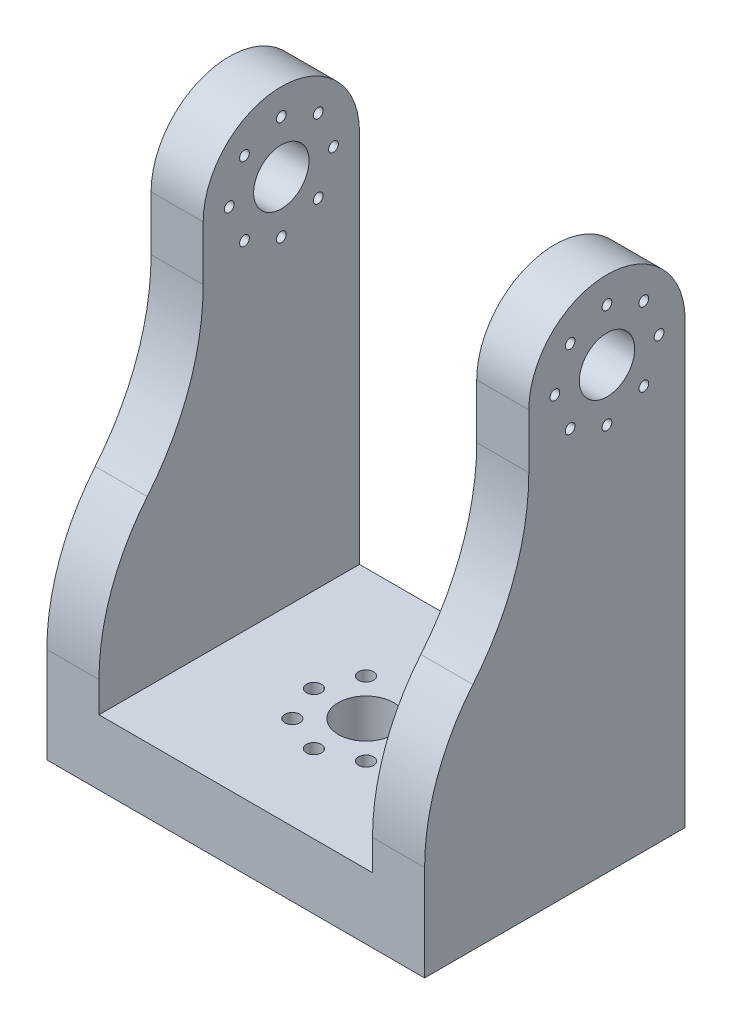
from build123d import *

# Parameters (mm, degrees)
DODANIE_WYCI_GNI_CIE1_DEPTH = 40
SZKIC2_R                    = 4.25
WYTNIJ_WYCI_GNI_CIE1_DEPTH  = 107.60206377
SZKIC3_R                    = 4.25
SZKIC3_R_2                  = 0.65
WYTNIJ_WYCI_GNI_CIE2_DEPTH  = 86.301617521
SZKIC4_R                    = 0.75
WYTNIJ_WYCI_GNI_CIE3_DEPTH  = 107.254891017
SZKIC3_3_R                  = 1.15
SZKIC3_3_R_2                = 0.65
WYTNIJ_WYCI_GNI_CIE4_DEPTH  = 4


with BuildPart() as part:
    # Szkic1 → Dodanie-wyci_gni_cie1 (new body)
    with BuildSketch(Plane.XY):
        Polygon((21, 10), (-21, 10), (-21, 80), (-29, 80), (-29, 0), (29, 0), (29, 80), (21, 80), align=None)
    extrude(amount=DODANIE_WYCI_GNI_CIE1_DEPTH)

    # Szkic2 → Wytnij-wyci_gni_cie1 (cut, through all)
    with BuildSketch(Plane(origin=(29, 0, 0), x_dir=(0, 0, -1), z_dir=(1, 0, 0))):
        with BuildLine():
            ThreePointArc((-24, 67.536795667), (-12, 79.536795667), (0, 67.536795667))
            Line((0, 67.536795667), (0, 80))
            Line((0, 80), (-40, 80))
            Line((-40, 80), (-40, 14.688889066))
            ThreePointArc((-40, 14.688889066), (-38.089938994, 25.648227934), (-32.584991767, 35.315233546))
            ThreePointArc((-32.584991767, 35.315233546), (-26.211441646, 46.507556061), (-24, 59.196123761))
            Line((-24, 59.196123761), (-24, 67.536795667))
        make_face()
        with Locations((-12, 67.536795667)):
            Circle(SZKIC2_R)
    extrude(amount=-WYTNIJ_WYCI_GNI_CIE1_DEPTH, mode=Mode.SUBTRACT)

    # Szkic3 → Wytnij-wyci_gni_cie2 (cut, through all)
    with BuildSketch(Plane(origin=(0, 10, 0), x_dir=(1, 0, 0), z_dir=(0, 1, 0))):
        with Locations((0, -20)):
            Circle(SZKIC3_R)
        with Locations((0, -12)):
            Circle(SZKIC3_R_2)
        with Locations((0, -28)):
            Circle(SZKIC3_R_2)
        with Locations((5.656854249, -25.656854249)):
            Circle(SZKIC3_R_2)
        with Locations((8, -20)):
            Circle(SZKIC3_R_2)
        with Locations((-5.656854249, -25.656854249)):
            Circle(SZKIC3_R_2)
        with Locations((-8, -20)):
            Circle(SZKIC3_R_2)
        with Locations((-5.656854249, -14.343145751)):
            Circle(SZKIC3_R_2)
        with Locations((5.656854249, -14.343145751)):
            Circle(SZKIC3_R_2)
    extrude(amount=-WYTNIJ_WYCI_GNI_CIE2_DEPTH, mode=Mode.SUBTRACT)

    # Szkic4 → Wytnij-wyci_gni_cie3 (cut, through all)
    with BuildSketch(Plane.ZY.offset(29)):
        with Locations((4, 67.536795667)):
            Circle(SZKIC4_R)
        with Locations((12, 75.536795667)):
            Circle(SZKIC4_R)
        with Locations((20, 67.536795667)):
            Circle(SZKIC4_R)
        with Locations((12, 59.536795667)):
            Circle(SZKIC4_R)
        with Locations((6.343145751, 61.879941418)):
            Circle(SZKIC4_R)
        with Locations((6.343145751, 73.193649917)):
            Circle(SZKIC4_R)
        with Locations((17.656854249, 73.193649917)):
            Circle(SZKIC4_R)
        with Locations((17.656854249, 61.879941418)):
            Circle(SZKIC4_R)
    extrude(amount=-WYTNIJ_WYCI_GNI_CIE3_DEPTH, mode=Mode.SUBTRACT)

    # Szkic3_3 → Wytnij-wyci_gni_cie4 (cut)
    # profile 1 of 8: a face of its own
    with BuildSketch(Plane(origin=(0, 10, 0), x_dir=(1, 0, 0), z_dir=(0, 1, 0))):
        with Locations((0, -12)):
            Circle(SZKIC3_3_R)
        with Locations((0, -12)):
            Circle(SZKIC3_3_R_2, mode=Mode.SUBTRACT)
    # profile 2 of 8: a face of its own
    with BuildSketch(Plane(origin=(0, 10, 0), x_dir=(1, 0, 0), z_dir=(0, 1, 0))):
        with Locations((0, -28)):
            Circle(SZKIC3_3_R)
        with Locations((0, -28)):
            Circle(SZKIC3_3_R_2, mode=Mode.SUBTRACT)
    # profile 3 of 8: a face of its own
    with BuildSketch(Plane(origin=(0, 10, 0), x_dir=(1, 0, 0), z_dir=(0, 1, 0))):
        with Locations((8, -20)):
            Circle(SZKIC3_3_R)
        with Locations((8, -20)):
            Circle(SZKIC3_3_R_2, mode=Mode.SUBTRACT)
    # profile 4 of 8: a face of its own
    with BuildSketch(Plane(origin=(0, 10, 0), x_dir=(1, 0, 0), z_dir=(0, 1, 0))):
        with Locations((5.656854249, -25.656854249)):
            Circle(SZKIC3_3_R)
        with Locations((5.656854249, -25.656854249)):
            Circle(SZKIC3_3_R_2, mode=Mode.SUBTRACT)
    # profile 5 of 8: a face of its own
    with BuildSketch(Plane(origin=(0, 10, 0), x_dir=(1, 0, 0), z_dir=(0, 1, 0))):
        with Locations((-5.656854249, -25.656854249)):
            Circle(SZKIC3_3_R)
        with Locations((-5.656854249, -25.656854249)):
            Circle(SZKIC3_3_R_2, mode=Mode.SUBTRACT)
    # profile 6 of 8: a face of its own
    with BuildSketch(Plane(origin=(0, 10, 0), x_dir=(1, 0, 0), z_dir=(0, 1, 0))):
        with Locations((-8, -20)):
            Circle(SZKIC3_3_R)
        with Locations((-8, -20)):
            Circle(SZKIC3_3_R_2, mode=Mode.SUBTRACT)
    # profile 7 of 8: a face of its own
    with BuildSketch(Plane(origin=(0, 10, 0), x_dir=(1, 0, 0), z_dir=(0, 1, 0))):
        with Locations((-5.656854249, -14.343145751)):
            Circle(SZKIC3_3_R)
        with Locations((-5.656854249, -14.343145751)):
            Circle(SZKIC3_3_R_2, mode=Mode.SUBTRACT)
    # profile 8 of 8: a face of its own
    with BuildSketch(Plane(origin=(0, 10, 0), x_dir=(1, 0, 0), z_dir=(0, 1, 0))):
        with Locations((5.656854249, -14.343145751)):
            Circle(SZKIC3_3_R)
        with Locations((5.656854249, -14.343145751)):
            Circle(SZKIC3_3_R_2, mode=Mode.SUBTRACT)
    extrude(amount=-WYTNIJ_WYCI_GNI_CIE4_DEPTH, mode=Mode.SUBTRACT)


solid = part.part
